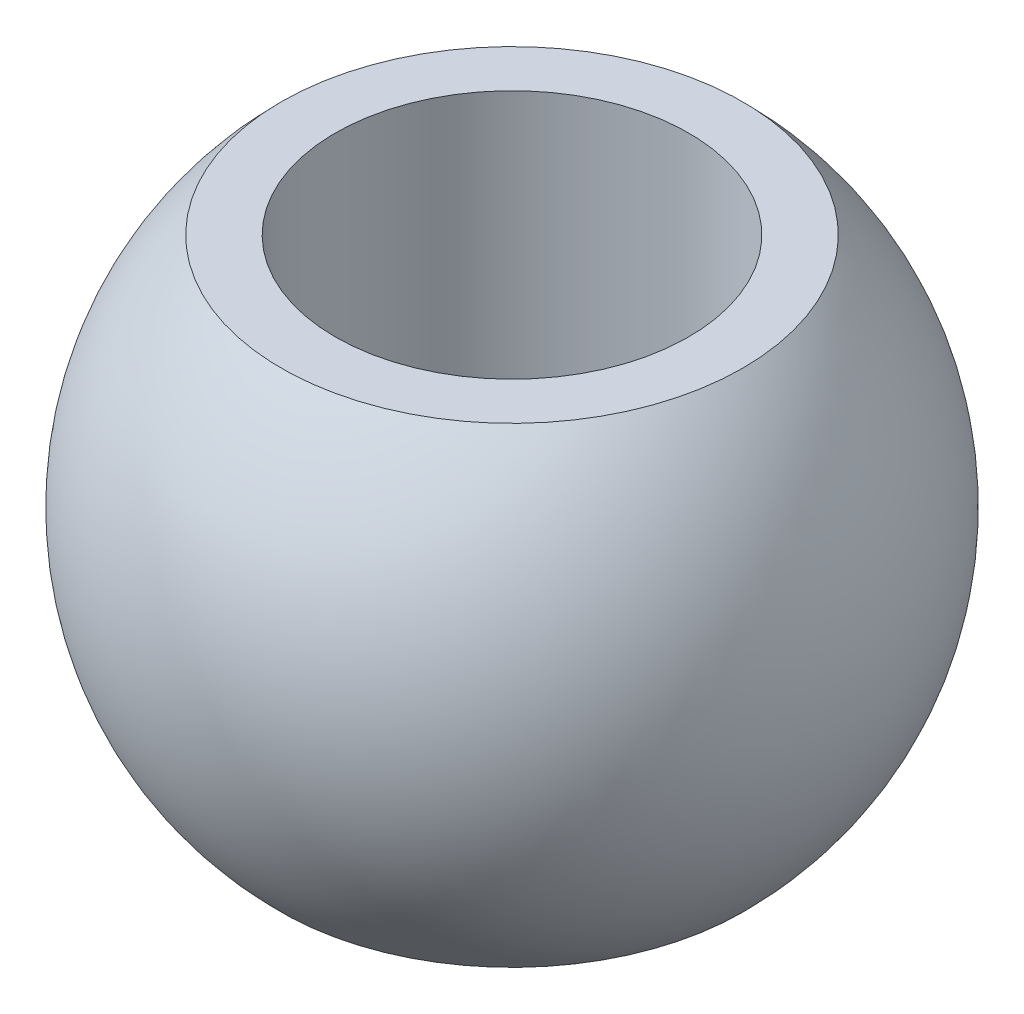
from build123d import *

# Parameters (mm, degrees)
SKETCH2_R          = 4.7625
CUT_EXTRUDE1_DEPTH = 13.7


with BuildPart() as part:
    # Sketch1 → Revolve1 (revolve)
    with BuildSketch(Plane.XY):
        with BuildLine():
            Line((4, 4.936203049), (4, -7.763796951))
            Line((4, -7.763796951), (6.219437776, -7.763796951))
            ThreePointArc((6.219437776, -7.763796951), (8.888414158, -1.413796951), (6.219437776, 4.936203049))
            Line((6.219437776, 4.936203049), (4, 4.936203049))
        make_face()
    revolve(axis=Axis((0, -9.351296951, 0), (0, 1, 0)))

    # Sketch2 → Cut-Extrude1 (cut, through all)
    with BuildSketch(Plane(origin=(0, 4.936203049, 0), x_dir=(1, 0, 0), z_dir=(0, 1, 0))):
        Circle(SKETCH2_R)
    extrude(amount=-CUT_EXTRUDE1_DEPTH, mode=Mode.SUBTRACT)


solid = part.part
